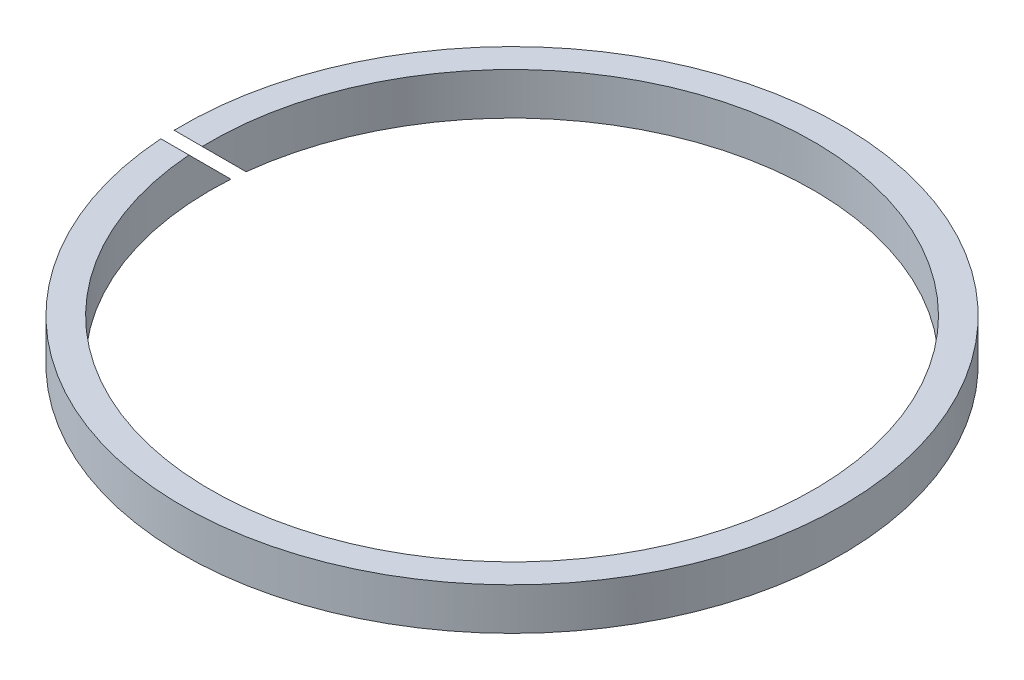
from build123d import *

# Parameters (mm, degrees)
SKETCH1_R           = 23.5
SKETCH1_R_2         = 21.5
BOSS_EXTRUDE1_DEPTH = 1.5
CUT_EXTRUDE1_REACH  = 25.5


with BuildPart() as part:
    # Sketch1 → Boss-Extrude1 (new body, symmetric)
    with BuildSketch(Plane(origin=(0, 0, 0), x_dir=(1, 0, 0), z_dir=(0, 1, 0))):
        Circle(SKETCH1_R)
        Circle(SKETCH1_R_2, mode=Mode.SUBTRACT)
    extrude(amount=BOSS_EXTRUDE1_DEPTH, both=True)

    # Sketch2 → Cut-Extrude1 (cut, up to next)
    with BuildSketch(Plane(origin=(0, 0, 0), x_dir=(0, 0, -1), z_dir=(1, 0, 0)), mode=Mode.PRIVATE) as cut_extrude1_sk1:
        Polygon((-1.593721188, 1.5), (1.406278812, -1.5), (2.406278812, -1.5), (-0.593721188, 1.5), align=None)
    cut_extrude1_tool1 = extrude(cut_extrude1_sk1.sketch, amount=-CUT_EXTRUDE1_REACH, mode=Mode.PRIVATE) & part.part
    add(cut_extrude1_tool1.solids().sort_by_distance((0, 0, -0.406279))[0], mode=Mode.SUBTRACT)


solid = part.part
